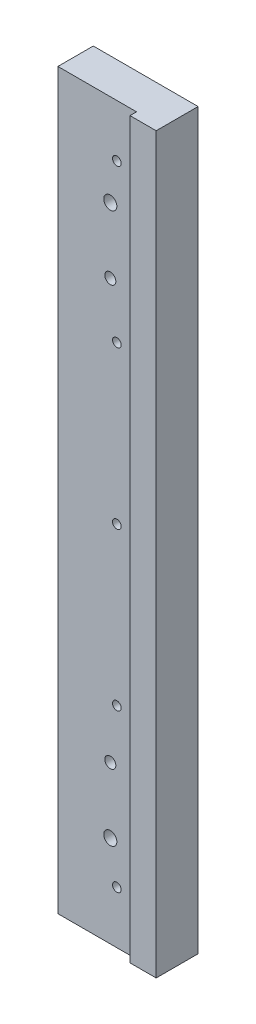
from build123d import *

# Parameters (mm, degrees)
SKETCH1_W             = 40
SKETCH1_H             = 280
EXTRUDE1_DEPTH        = 16
EXTRUDE2_REACH        = 282
SKETCH2_W             = 30
SKETCH2_H             = 2.5
M4_TAPPED_HOLE1_D     = 3.3
M6_TAPPED_HOLE1_D     = 5
M5_TAPPED_HOLE1_D     = 4.2
M5_TAPPED_HOLE1_DEPTH = 13.5


with BuildPart() as part:
    # Sketch1 → Extrude1 (new body)
    with BuildSketch(Plane.XY):
        Rectangle(SKETCH1_W, SKETCH1_H)
    extrude(amount=EXTRUDE1_DEPTH)

    # Sketch2 → Extrude2 (cut, up to next)
    with BuildSketch(Plane.XZ.offset(140), mode=Mode.PRIVATE) as extrude2_sk1:
        with Locations((-5, 14.75)):
            Rectangle(SKETCH2_W, SKETCH2_H)
    extrude2_tool1 = extrude(extrude2_sk1.sketch, amount=-EXTRUDE2_REACH, mode=Mode.PRIVATE) & part.part
    add(extrude2_tool1.solids().sort_by_distance((-5, -140, 14.75))[0], mode=Mode.SUBTRACT)

    # M4 Tapped Hole1 (through all)
    with Locations(Plane.XY.offset(13.5)):
        with Locations((2.5, -120), (2.5, -60), (2.5, 0), (2.5, 60), (2.5, 120)):
            Hole(M4_TAPPED_HOLE1_D / 2)

    # M6 Tapped Hole1 (through all)
    with Locations(Plane(origin=(0, 0, 0), x_dir=(-1, 0, 0), z_dir=(0, 0, -1))):
        with Locations((0, 105), (0, -105)):
            Hole(M6_TAPPED_HOLE1_D / 2)

    # M5 Tapped Hole1
    with Locations(Plane.XY.offset(13.5)):
        with Locations((0, 80), (0, -80)):
            Hole(M5_TAPPED_HOLE1_D / 2, depth=M5_TAPPED_HOLE1_DEPTH)


solid = part.part
